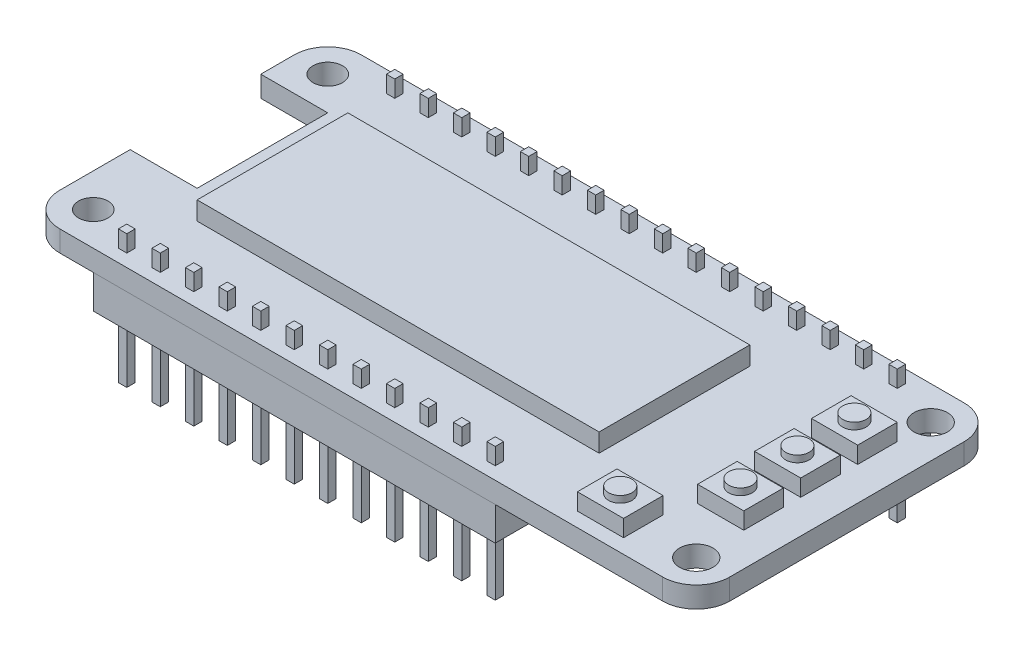
from build123d import *

# Parameters (mm, degrees)
SKETCH1_R                   = 1.27
SKETCH1_R_2                 = 1.1176
BOSS_EXTRUDE1_DEPTH         = 1.5875
SKETCH2_W                   = 0.635
SKETCH2_H                   = 0.635
BOSS_EXTRUDE3_DEPTH         = 2.8575
BOSS_EXTRUDE3_DEPTH_BACK    = 7.239
BOSS_EXTRUDE3_2_DEPTH       = 2.8575
BOSS_EXTRUDE3_2_DEPTH_BACK  = 7.239
BOSS_EXTRUDE3_3_DEPTH       = 2.8575
BOSS_EXTRUDE3_3_DEPTH_BACK  = 7.239
BOSS_EXTRUDE3_4_DEPTH       = 2.8575
BOSS_EXTRUDE3_4_DEPTH_BACK  = 7.239
BOSS_EXTRUDE3_5_DEPTH       = 2.8575
BOSS_EXTRUDE3_5_DEPTH_BACK  = 7.239
BOSS_EXTRUDE3_6_DEPTH       = 2.8575
BOSS_EXTRUDE3_6_DEPTH_BACK  = 7.239
BOSS_EXTRUDE3_7_DEPTH       = 2.8575
BOSS_EXTRUDE3_7_DEPTH_BACK  = 7.239
BOSS_EXTRUDE3_8_DEPTH       = 2.8575
BOSS_EXTRUDE3_8_DEPTH_BACK  = 7.239
BOSS_EXTRUDE3_9_DEPTH       = 2.8575
BOSS_EXTRUDE3_9_DEPTH_BACK  = 7.239
BOSS_EXTRUDE3_10_DEPTH      = 2.8575
BOSS_EXTRUDE3_10_DEPTH_BACK = 7.239
BOSS_EXTRUDE3_11_DEPTH      = 2.8575
BOSS_EXTRUDE3_11_DEPTH_BACK = 7.239
BOSS_EXTRUDE3_12_DEPTH      = 2.8575
BOSS_EXTRUDE3_12_DEPTH_BACK = 7.239
BOSS_EXTRUDE3_13_DEPTH      = 2.8575
BOSS_EXTRUDE3_13_DEPTH_BACK = 7.239
BOSS_EXTRUDE3_14_DEPTH      = 2.8575
BOSS_EXTRUDE3_14_DEPTH_BACK = 7.239
BOSS_EXTRUDE3_15_DEPTH      = 2.8575
BOSS_EXTRUDE3_15_DEPTH_BACK = 7.239
BOSS_EXTRUDE3_16_DEPTH      = 2.8575
BOSS_EXTRUDE3_16_DEPTH_BACK = 7.239
BOSS_EXTRUDE3_17_DEPTH      = 2.8575
BOSS_EXTRUDE3_17_DEPTH_BACK = 7.239
BOSS_EXTRUDE3_18_DEPTH      = 2.8575
BOSS_EXTRUDE3_18_DEPTH_BACK = 7.239
BOSS_EXTRUDE3_19_DEPTH      = 2.8575
BOSS_EXTRUDE3_19_DEPTH_BACK = 7.239
BOSS_EXTRUDE3_20_DEPTH      = 2.8575
BOSS_EXTRUDE3_20_DEPTH_BACK = 7.239
BOSS_EXTRUDE3_21_DEPTH      = 2.8575
BOSS_EXTRUDE3_21_DEPTH_BACK = 7.239
BOSS_EXTRUDE3_22_DEPTH      = 2.8575
BOSS_EXTRUDE3_22_DEPTH_BACK = 7.239
BOSS_EXTRUDE3_23_DEPTH      = 2.8575
BOSS_EXTRUDE3_23_DEPTH_BACK = 7.239
BOSS_EXTRUDE3_24_DEPTH      = 2.8575
BOSS_EXTRUDE3_24_DEPTH_BACK = 7.239
BOSS_EXTRUDE3_25_DEPTH      = 2.8575
BOSS_EXTRUDE3_25_DEPTH_BACK = 7.239
BOSS_EXTRUDE3_26_DEPTH      = 2.8575
BOSS_EXTRUDE3_26_DEPTH_BACK = 7.239
BOSS_EXTRUDE3_27_DEPTH      = 2.8575
BOSS_EXTRUDE3_27_DEPTH_BACK = 7.239
BOSS_EXTRUDE3_28_DEPTH      = 2.8575
BOSS_EXTRUDE3_28_DEPTH_BACK = 7.239
SKETCH3_W                   = 40.64
SKETCH3_H                   = 2.54
BOSS_EXTRUDE4_DEPTH         = 2.54
SKETCH3_W_2                 = 30.48
BOSS_EXTRUDE4_2_DEPTH       = 2.54
SKETCH4_W                   = 30.48
SKETCH4_H                   = 11.43
BOSS_EXTRUDE5_DEPTH         = 1.397
SKETCH5_W                   = 3.5
SKETCH5_H                   = 3
BOSS_EXTRUDE6_DEPTH         = 1.27
SKETCH5_3_R                 = 0.889
BOSS_EXTRUDE8_DEPTH         = 1.778


with BuildPart() as part:
    # Sketch1 → Boss-Extrude1 (new body)
    with BuildSketch(Plane(origin=(0, 0, 0), x_dir=(1, 0, 0), z_dir=(0, 1, 0))):
        with BuildLine():
            Line((2.54, 0), (48.26, 0))
            ThreePointArc((48.26, 0), (50.056051224, 0.743948776), (50.8, 2.54))
            Line((50.8, 2.54), (50.8, 20.32))
            ThreePointArc((50.8, 20.32), (50.056051224, 22.116051224), (48.26, 22.86))
            Line((48.26, 22.86), (2.54, 22.86))
            ThreePointArc((2.54, 22.86), (0.743948776, 22.116051224), (0, 20.32))
            Line((0, 20.32), (0, 17.78))
            Line((0, 17.78), (5.08, 17.78))
            Line((5.08, 17.78), (5.08, 7.874))
            Line((5.08, 7.874), (0, 7.874))
            Line((0, 7.874), (0, 2.54))
            ThreePointArc((0, 2.54), (0.743948776, 0.743948776), (2.54, 0))
        make_face()
        with Locations((48.26, 20.32)):
            Circle(SKETCH1_R, mode=Mode.SUBTRACT)
        with Locations((48.26, 2.54)):
            Circle(SKETCH1_R, mode=Mode.SUBTRACT)
        with Locations((2.54, 20.32)):
            Circle(SKETCH1_R_2, mode=Mode.SUBTRACT)
        with Locations((2.54, 2.54)):
            Circle(SKETCH1_R_2, mode=Mode.SUBTRACT)
    extrude(amount=BOSS_EXTRUDE1_DEPTH)

    # Sketch4 → Boss-Extrude5 (add)
    with BuildSketch(Plane(origin=(0, 1.5875, 0), x_dir=(1, 0, 0), z_dir=(0, 1, 0))):
        with Locations((22.479, 11.43)):
            Rectangle(SKETCH4_W, SKETCH4_H)
    extrude(amount=BOSS_EXTRUDE5_DEPTH)

    # Sketch5 → Boss-Extrude6 (add)
    with BuildSketch(Plane(origin=(0, 1.5875, 0), x_dir=(1, 0, 0), z_dir=(0, 1, 0))):
        with Locations((46.51, 16.28)):
            Rectangle(SKETCH5_W, SKETCH5_H)
        with Locations((46.51, 11.962)):
            Rectangle(SKETCH5_W, SKETCH5_H)
        with Locations((46.51, 7.644)):
            Rectangle(SKETCH5_W, SKETCH5_H)
        with Locations((42.446, 2.5922)):
            Rectangle(SKETCH5_W, SKETCH5_H)
    extrude(amount=BOSS_EXTRUDE6_DEPTH)

    # Sketch5_3 → Boss-Extrude8 (add)
    with BuildSketch(Plane(origin=(0, 1.5875, 0), x_dir=(1, 0, 0), z_dir=(0, 1, 0))):
        with Locations((46.51, 16.28)):
            Circle(SKETCH5_3_R)
        with Locations((46.51, 11.962)):
            Circle(SKETCH5_3_R)
        with Locations((46.51, 7.644)):
            Circle(SKETCH5_3_R)
        with Locations((42.446, 2.5922)):
            Circle(SKETCH5_3_R)
    extrude(amount=BOSS_EXTRUDE8_DEPTH)


with BuildPart() as body_2:
    # Sketch2 → Boss-Extrude3 (new body, two sides)
    with BuildSketch(Plane(origin=(0, 0, 0), x_dir=(1, 0, 0), z_dir=(0, 1, 0))) as boss_extrude3_sk:
        with Locations((8.89, 1.27)):
            Rectangle(SKETCH2_W, SKETCH2_H)
    extrude(amount=BOSS_EXTRUDE3_DEPTH)
    extrude(boss_extrude3_sk.sketch, amount=-BOSS_EXTRUDE3_DEPTH_BACK)


with BuildPart() as body_3:
    # Sketch2 → Boss-Extrude3 2 (new body, two sides)
    with BuildSketch(Plane(origin=(0, 0, 0), x_dir=(1, 0, 0), z_dir=(0, 1, 0))) as boss_extrude3_2_sk:
        with Locations((6.35, 1.27)):
            Rectangle(SKETCH2_W, SKETCH2_H)
    extrude(amount=BOSS_EXTRUDE3_2_DEPTH)
    extrude(boss_extrude3_2_sk.sketch, amount=-BOSS_EXTRUDE3_2_DEPTH_BACK)


with BuildPart() as body_4:
    # Sketch2 → Boss-Extrude3 3 (new body, two sides)
    with BuildSketch(Plane(origin=(0, 0, 0), x_dir=(1, 0, 0), z_dir=(0, 1, 0))) as boss_extrude3_3_sk:
        with Locations((11.43, 1.27)):
            Rectangle(SKETCH2_W, SKETCH2_H)
    extrude(amount=BOSS_EXTRUDE3_3_DEPTH)
    extrude(boss_extrude3_3_sk.sketch, amount=-BOSS_EXTRUDE3_3_DEPTH_BACK)


with BuildPart() as body_5:
    # Sketch2 → Boss-Extrude3 4 (new body, two sides)
    with BuildSketch(Plane(origin=(0, 0, 0), x_dir=(1, 0, 0), z_dir=(0, 1, 0))) as boss_extrude3_4_sk:
        with Locations((13.97, 1.27)):
            Rectangle(SKETCH2_W, SKETCH2_H)
    extrude(amount=BOSS_EXTRUDE3_4_DEPTH)
    extrude(boss_extrude3_4_sk.sketch, amount=-BOSS_EXTRUDE3_4_DEPTH_BACK)


with BuildPart() as body_6:
    # Sketch2 → Boss-Extrude3 5 (new body, two sides)
    with BuildSketch(Plane(origin=(0, 0, 0), x_dir=(1, 0, 0), z_dir=(0, 1, 0))) as boss_extrude3_5_sk:
        with Locations((16.51, 1.27)):
            Rectangle(SKETCH2_W, SKETCH2_H)
    extrude(amount=BOSS_EXTRUDE3_5_DEPTH)
    extrude(boss_extrude3_5_sk.sketch, amount=-BOSS_EXTRUDE3_5_DEPTH_BACK)


with BuildPart() as body_7:
    # Sketch2 → Boss-Extrude3 6 (new body, two sides)
    with BuildSketch(Plane(origin=(0, 0, 0), x_dir=(1, 0, 0), z_dir=(0, 1, 0))) as boss_extrude3_6_sk:
        with Locations((19.05, 1.27)):
            Rectangle(SKETCH2_W, SKETCH2_H)
    extrude(amount=BOSS_EXTRUDE3_6_DEPTH)
    extrude(boss_extrude3_6_sk.sketch, amount=-BOSS_EXTRUDE3_6_DEPTH_BACK)


with BuildPart() as body_8:
    # Sketch2 → Boss-Extrude3 7 (new body, two sides)
    with BuildSketch(Plane(origin=(0, 0, 0), x_dir=(1, 0, 0), z_dir=(0, 1, 0))) as boss_extrude3_7_sk:
        with Locations((21.59, 1.27)):
            Rectangle(SKETCH2_W, SKETCH2_H)
    extrude(amount=BOSS_EXTRUDE3_7_DEPTH)
    extrude(boss_extrude3_7_sk.sketch, amount=-BOSS_EXTRUDE3_7_DEPTH_BACK)


with BuildPart() as body_9:
    # Sketch2 → Boss-Extrude3 8 (new body, two sides)
    with BuildSketch(Plane(origin=(0, 0, 0), x_dir=(1, 0, 0), z_dir=(0, 1, 0))) as boss_extrude3_8_sk:
        with Locations((24.13, 1.27)):
            Rectangle(SKETCH2_W, SKETCH2_H)
    extrude(amount=BOSS_EXTRUDE3_8_DEPTH)
    extrude(boss_extrude3_8_sk.sketch, amount=-BOSS_EXTRUDE3_8_DEPTH_BACK)


with BuildPart() as body_10:
    # Sketch2 → Boss-Extrude3 9 (new body, two sides)
    with BuildSketch(Plane(origin=(0, 0, 0), x_dir=(1, 0, 0), z_dir=(0, 1, 0))) as boss_extrude3_9_sk:
        with Locations((26.67, 1.27)):
            Rectangle(SKETCH2_W, SKETCH2_H)
    extrude(amount=BOSS_EXTRUDE3_9_DEPTH)
    extrude(boss_extrude3_9_sk.sketch, amount=-BOSS_EXTRUDE3_9_DEPTH_BACK)


with BuildPart() as body_11:
    # Sketch2 → Boss-Extrude3 10 (new body, two sides)
    with BuildSketch(Plane(origin=(0, 0, 0), x_dir=(1, 0, 0), z_dir=(0, 1, 0))) as boss_extrude3_10_sk:
        with Locations((29.21, 1.27)):
            Rectangle(SKETCH2_W, SKETCH2_H)
    extrude(amount=BOSS_EXTRUDE3_10_DEPTH)
    extrude(boss_extrude3_10_sk.sketch, amount=-BOSS_EXTRUDE3_10_DEPTH_BACK)


with BuildPart() as body_12:
    # Sketch2 → Boss-Extrude3 11 (new body, two sides)
    with BuildSketch(Plane(origin=(0, 0, 0), x_dir=(1, 0, 0), z_dir=(0, 1, 0))) as boss_extrude3_11_sk:
        with Locations((31.75, 1.27)):
            Rectangle(SKETCH2_W, SKETCH2_H)
    extrude(amount=BOSS_EXTRUDE3_11_DEPTH)
    extrude(boss_extrude3_11_sk.sketch, amount=-BOSS_EXTRUDE3_11_DEPTH_BACK)


with BuildPart() as body_13:
    # Sketch2 → Boss-Extrude3 12 (new body, two sides)
    with BuildSketch(Plane(origin=(0, 0, 0), x_dir=(1, 0, 0), z_dir=(0, 1, 0))) as boss_extrude3_12_sk:
        with Locations((34.29, 1.27)):
            Rectangle(SKETCH2_W, SKETCH2_H)
    extrude(amount=BOSS_EXTRUDE3_12_DEPTH)
    extrude(boss_extrude3_12_sk.sketch, amount=-BOSS_EXTRUDE3_12_DEPTH_BACK)


with BuildPart() as body_14:
    # Sketch2 → Boss-Extrude3 13 (new body, two sides)
    with BuildSketch(Plane(origin=(0, 0, 0), x_dir=(1, 0, 0), z_dir=(0, 1, 0))) as boss_extrude3_13_sk:
        with Locations((8.89, 21.59)):
            Rectangle(SKETCH2_W, SKETCH2_H)
    extrude(amount=BOSS_EXTRUDE3_13_DEPTH)
    extrude(boss_extrude3_13_sk.sketch, amount=-BOSS_EXTRUDE3_13_DEPTH_BACK)


with BuildPart() as body_15:
    # Sketch2 → Boss-Extrude3 14 (new body, two sides)
    with BuildSketch(Plane(origin=(0, 0, 0), x_dir=(1, 0, 0), z_dir=(0, 1, 0))) as boss_extrude3_14_sk:
        with Locations((6.35, 21.59)):
            Rectangle(SKETCH2_W, SKETCH2_H)
    extrude(amount=BOSS_EXTRUDE3_14_DEPTH)
    extrude(boss_extrude3_14_sk.sketch, amount=-BOSS_EXTRUDE3_14_DEPTH_BACK)


with BuildPart() as body_16:
    # Sketch2 → Boss-Extrude3 15 (new body, two sides)
    with BuildSketch(Plane(origin=(0, 0, 0), x_dir=(1, 0, 0), z_dir=(0, 1, 0))) as boss_extrude3_15_sk:
        with Locations((11.43, 21.59)):
            Rectangle(SKETCH2_W, SKETCH2_H)
    extrude(amount=BOSS_EXTRUDE3_15_DEPTH)
    extrude(boss_extrude3_15_sk.sketch, amount=-BOSS_EXTRUDE3_15_DEPTH_BACK)


with BuildPart() as body_17:
    # Sketch2 → Boss-Extrude3 16 (new body, two sides)
    with BuildSketch(Plane(origin=(0, 0, 0), x_dir=(1, 0, 0), z_dir=(0, 1, 0))) as boss_extrude3_16_sk:
        with Locations((13.97, 21.59)):
            Rectangle(SKETCH2_W, SKETCH2_H)
    extrude(amount=BOSS_EXTRUDE3_16_DEPTH)
    extrude(boss_extrude3_16_sk.sketch, amount=-BOSS_EXTRUDE3_16_DEPTH_BACK)


with BuildPart() as body_18:
    # Sketch2 → Boss-Extrude3 17 (new body, two sides)
    with BuildSketch(Plane(origin=(0, 0, 0), x_dir=(1, 0, 0), z_dir=(0, 1, 0))) as boss_extrude3_17_sk:
        with Locations((16.51, 21.59)):
            Rectangle(SKETCH2_W, SKETCH2_H)
    extrude(amount=BOSS_EXTRUDE3_17_DEPTH)
    extrude(boss_extrude3_17_sk.sketch, amount=-BOSS_EXTRUDE3_17_DEPTH_BACK)


with BuildPart() as body_19:
    # Sketch2 → Boss-Extrude3 18 (new body, two sides)
    with BuildSketch(Plane(origin=(0, 0, 0), x_dir=(1, 0, 0), z_dir=(0, 1, 0))) as boss_extrude3_18_sk:
        with Locations((19.05, 21.59)):
            Rectangle(SKETCH2_W, SKETCH2_H)
    extrude(amount=BOSS_EXTRUDE3_18_DEPTH)
    extrude(boss_extrude3_18_sk.sketch, amount=-BOSS_EXTRUDE3_18_DEPTH_BACK)


with BuildPart() as body_20:
    # Sketch2 → Boss-Extrude3 19 (new body, two sides)
    with BuildSketch(Plane(origin=(0, 0, 0), x_dir=(1, 0, 0), z_dir=(0, 1, 0))) as boss_extrude3_19_sk:
        with Locations((21.59, 21.59)):
            Rectangle(SKETCH2_W, SKETCH2_H)
    extrude(amount=BOSS_EXTRUDE3_19_DEPTH)
    extrude(boss_extrude3_19_sk.sketch, amount=-BOSS_EXTRUDE3_19_DEPTH_BACK)


with BuildPart() as body_21:
    # Sketch2 → Boss-Extrude3 20 (new body, two sides)
    with BuildSketch(Plane(origin=(0, 0, 0), x_dir=(1, 0, 0), z_dir=(0, 1, 0))) as boss_extrude3_20_sk:
        with Locations((24.13, 21.59)):
            Rectangle(SKETCH2_W, SKETCH2_H)
    extrude(amount=BOSS_EXTRUDE3_20_DEPTH)
    extrude(boss_extrude3_20_sk.sketch, amount=-BOSS_EXTRUDE3_20_DEPTH_BACK)


with BuildPart() as body_22:
    # Sketch2 → Boss-Extrude3 21 (new body, two sides)
    with BuildSketch(Plane(origin=(0, 0, 0), x_dir=(1, 0, 0), z_dir=(0, 1, 0))) as boss_extrude3_21_sk:
        with Locations((26.67, 21.59)):
            Rectangle(SKETCH2_W, SKETCH2_H)
    extrude(amount=BOSS_EXTRUDE3_21_DEPTH)
    extrude(boss_extrude3_21_sk.sketch, amount=-BOSS_EXTRUDE3_21_DEPTH_BACK)


with BuildPart() as body_23:
    # Sketch2 → Boss-Extrude3 22 (new body, two sides)
    with BuildSketch(Plane(origin=(0, 0, 0), x_dir=(1, 0, 0), z_dir=(0, 1, 0))) as boss_extrude3_22_sk:
        with Locations((29.21, 21.59)):
            Rectangle(SKETCH2_W, SKETCH2_H)
    extrude(amount=BOSS_EXTRUDE3_22_DEPTH)
    extrude(boss_extrude3_22_sk.sketch, amount=-BOSS_EXTRUDE3_22_DEPTH_BACK)


with BuildPart() as body_24:
    # Sketch2 → Boss-Extrude3 23 (new body, two sides)
    with BuildSketch(Plane(origin=(0, 0, 0), x_dir=(1, 0, 0), z_dir=(0, 1, 0))) as boss_extrude3_23_sk:
        with Locations((31.75, 21.59)):
            Rectangle(SKETCH2_W, SKETCH2_H)
    extrude(amount=BOSS_EXTRUDE3_23_DEPTH)
    extrude(boss_extrude3_23_sk.sketch, amount=-BOSS_EXTRUDE3_23_DEPTH_BACK)


with BuildPart() as body_25:
    # Sketch2 → Boss-Extrude3 24 (new body, two sides)
    with BuildSketch(Plane(origin=(0, 0, 0), x_dir=(1, 0, 0), z_dir=(0, 1, 0))) as boss_extrude3_24_sk:
        with Locations((34.29, 21.59)):
            Rectangle(SKETCH2_W, SKETCH2_H)
    extrude(amount=BOSS_EXTRUDE3_24_DEPTH)
    extrude(boss_extrude3_24_sk.sketch, amount=-BOSS_EXTRUDE3_24_DEPTH_BACK)


with BuildPart() as body_26:
    # Sketch2 → Boss-Extrude3 25 (new body, two sides)
    with BuildSketch(Plane(origin=(0, 0, 0), x_dir=(1, 0, 0), z_dir=(0, 1, 0))) as boss_extrude3_25_sk:
        with Locations((36.83, 21.59)):
            Rectangle(SKETCH2_W, SKETCH2_H)
    extrude(amount=BOSS_EXTRUDE3_25_DEPTH)
    extrude(boss_extrude3_25_sk.sketch, amount=-BOSS_EXTRUDE3_25_DEPTH_BACK)


with BuildPart() as body_27:
    # Sketch2 → Boss-Extrude3 26 (new body, two sides)
    with BuildSketch(Plane(origin=(0, 0, 0), x_dir=(1, 0, 0), z_dir=(0, 1, 0))) as boss_extrude3_26_sk:
        with Locations((39.37, 21.59)):
            Rectangle(SKETCH2_W, SKETCH2_H)
    extrude(amount=BOSS_EXTRUDE3_26_DEPTH)
    extrude(boss_extrude3_26_sk.sketch, amount=-BOSS_EXTRUDE3_26_DEPTH_BACK)


with BuildPart() as body_28:
    # Sketch2 → Boss-Extrude3 27 (new body, two sides)
    with BuildSketch(Plane(origin=(0, 0, 0), x_dir=(1, 0, 0), z_dir=(0, 1, 0))) as boss_extrude3_27_sk:
        with Locations((41.91, 21.59)):
            Rectangle(SKETCH2_W, SKETCH2_H)
    extrude(amount=BOSS_EXTRUDE3_27_DEPTH)
    extrude(boss_extrude3_27_sk.sketch, amount=-BOSS_EXTRUDE3_27_DEPTH_BACK)


with BuildPart() as body_29:
    # Sketch2 → Boss-Extrude3 28 (new body, two sides)
    with BuildSketch(Plane(origin=(0, 0, 0), x_dir=(1, 0, 0), z_dir=(0, 1, 0))) as boss_extrude3_28_sk:
        with Locations((44.45, 21.59)):
            Rectangle(SKETCH2_W, SKETCH2_H)
    extrude(amount=BOSS_EXTRUDE3_28_DEPTH)
    extrude(boss_extrude3_28_sk.sketch, amount=-BOSS_EXTRUDE3_28_DEPTH_BACK)


with BuildPart() as body_30:
    # Sketch3 → Boss-Extrude4 (new body)
    with BuildSketch(Plane.XZ):
        with Locations((25.4, -21.59)):
            Rectangle(SKETCH3_W, SKETCH3_H)
    extrude(amount=BOSS_EXTRUDE4_DEPTH)


with BuildPart() as body_31:
    # Sketch3 → Boss-Extrude4 2 (new body)
    with BuildSketch(Plane.XZ):
        with Locations((20.32, -1.27)):
            Rectangle(SKETCH3_W_2, SKETCH3_H)
    extrude(amount=BOSS_EXTRUDE4_2_DEPTH)


solid = Compound([part.part, body_2.part, body_3.part, body_4.part, body_5.part, body_6.part, body_7.part, body_8.part, body_9.part, body_10.part, body_11.part, body_12.part, body_13.part, body_14.part, body_15.part, body_16.part, body_17.part, body_18.part, body_19.part, body_20.part, body_21.part, body_22.part, body_23.part, body_24.part, body_25.part, body_26.part, body_27.part, body_28.part, body_29.part, body_30.part, body_31.part])
